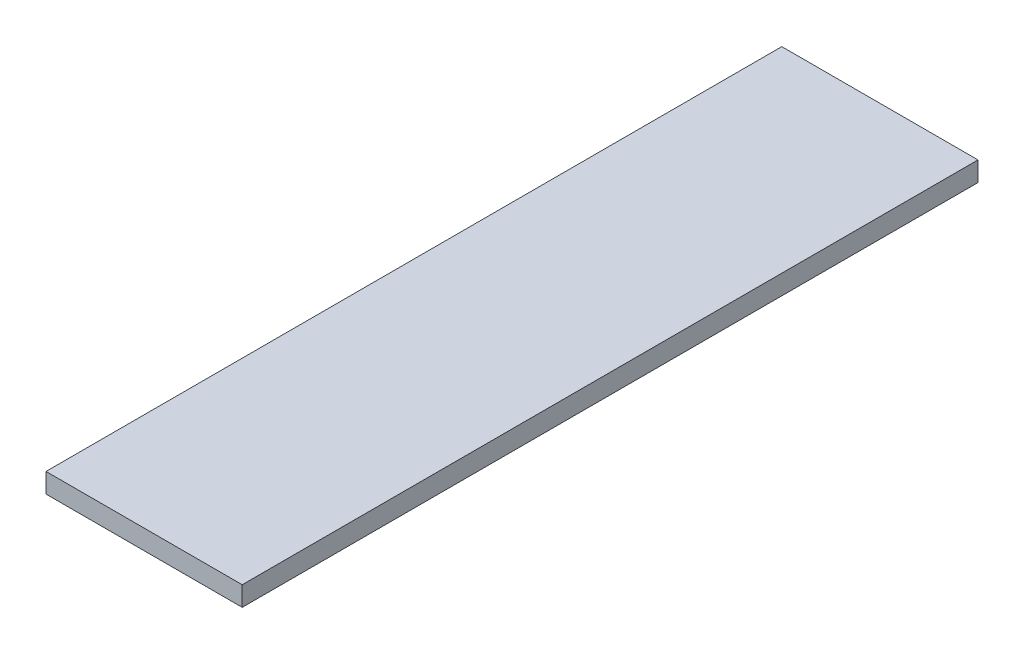
from build123d import *

# Parameters (mm, degrees)
ESBO_O1_W                = 200
ESBO_O1_H                = 20
RESSALTO_EXTRUS_O1_DEPTH = 750


with BuildPart() as part:
    # Esboço1 → Ressalto-extrusão1 (new body)
    with BuildSketch(Plane.XY):
        with Locations((-139.79814146, 43.625954198)):
            Rectangle(ESBO_O1_W, ESBO_O1_H)
    extrude(amount=RESSALTO_EXTRUS_O1_DEPTH)


solid = part.part
